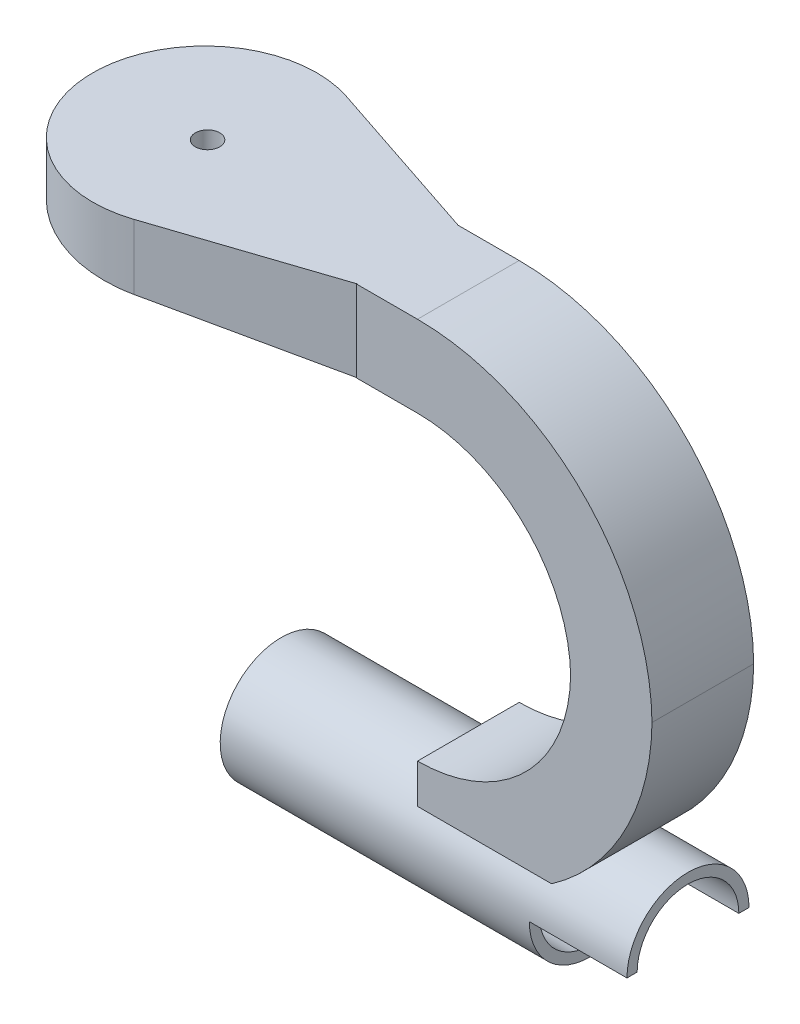
from build123d import *

# Parameters (mm, degrees)
BOSS_EXTRUDE2_DEPTH      = 25
BOSS_EXTRUDE4_DEPTH      = 20
BOSS_EXTRUDE5_DEPTH      = 46
BOSS_EXTRUDE5_DEPTH_BACK = 54
SKETCH2_R                = 15
CUT_EXTRUDE1_DEPTH       = 95
SKETCH6_R                = 3
CUT_EXTRUDE2_DEPTH       = 24
CUT_EXTRUDE3_DEPTH       = 149.259919116
CUT_EXTRUDE3_DEPTH_BACK  = 149.259919116
CUT_EXTRUDE5_DEPTH       = 24
SKETCH11_R               = 2.435
CUT_EXTRUDE6_DEPTH       = 132.297538714
CUT_EXTRUDE7_START       = -12
CUT_EXTRUDE7_DEPTH       = 10


with BuildPart() as part:
    # Sketch1 → Boss-Extrude2 (new body)
    with BuildSketch(Plane.XY):
        with BuildLine():
            ThreePointArc((-32.057903297, 37.033246562), (-5.652702459, 26.223247911), (5.591494761, 0))
            ThreePointArc((5.591494761, 0), (-5.652702459, -26.223247911), (-32.057903297, -37.033246562))
            Line((-32.057903297, -37.033246562), (-32.057903297, -57.033246562))
            ThreePointArc((-32.057903297, -57.033246562), (8.489751808, -40.365693604), (25.593272966, 0))
            ThreePointArc((25.593272966, 0), (8.489751808, 40.365693604), (-32.057903297, 57.033246562))
            Line((-32.057903297, 57.033246562), (-47.057903297, 57.033246562))
            Line((-47.057903297, 57.033246562), (-47.057903297, 37.033246562))
            Line((-47.057903297, 37.033246562), (-32.057903297, 37.033246562))
        make_face()
    extrude(amount=BOSS_EXTRUDE2_DEPTH)

    # Sketch3 → Boss-Extrude4 (add)
    with BuildSketch(Plane(origin=(0, 57.033246562, 0), x_dir=(1, 0, 0), z_dir=(0, 1, 0))):
        with BuildLine():
            Line((-47.057903297, -24.901242643), (-47.057903297, 0))
            Line((-47.057903297, 0), (-88.188861039, 13.690366027))
            ThreePointArc((-88.188861039, 13.690366027), (-124.440854646, -12.450621321), (-88.188861039, -38.591608669))
            Line((-88.188861039, -38.591608669), (-47.057903297, -24.901242643))
        make_face()
    extrude(amount=-BOSS_EXTRUDE4_DEPTH)

    # Sketch2 → Boss-Extrude5 (add, two sides: drawn at the far end of the back side and taken through both)
    with BuildSketch(Plane.ZY.offset(32.057903297).offset(-BOSS_EXTRUDE5_DEPTH_BACK)):
        with Locations((12.5, -54.966753438)):
            Circle(SKETCH2_R)
    extrude(amount=BOSS_EXTRUDE5_DEPTH + BOSS_EXTRUDE5_DEPTH_BACK)

    # Sketch5 → Cut-Extrude1 (cut)
    with BuildSketch(Plane(origin=(21.942096703, 0, 0), x_dir=(0, 0, -1), z_dir=(1, 0, 0))):
        with BuildLine():
            ThreePointArc((-25, -54.966753438), (-12.5, -67.466753438), (0, -54.966753438))
            ThreePointArc((0, -54.966753438), (-12.5, -42.466753438), (-25, -54.966753438))
        make_face()
    extrude(amount=-CUT_EXTRUDE1_DEPTH, mode=Mode.SUBTRACT)

    # Sketch6 → Cut-Extrude2 (cut)
    with BuildSketch(Plane(origin=(0, 57.033246562, 0), x_dir=(1, 0, 0), z_dir=(0, 1, 0))):
        with Locations((-96.052193002, -12.606102104)):
            Circle(SKETCH6_R)
    extrude(amount=-CUT_EXTRUDE2_DEPTH, mode=Mode.SUBTRACT)

    # Sketch7 → Cut-Extrude3 (cut, two sides: drawn at the far end of the back side and taken through both)
    with BuildSketch(Plane.XY.offset(-CUT_EXTRUDE3_DEPTH_BACK)):
        Polygon((-124.440854646, 44.571784262), (-47.057903297, 37.033246562), (-124.440854646, 37.033246562), align=None)
    extrude(amount=CUT_EXTRUDE3_DEPTH + CUT_EXTRUDE3_DEPTH_BACK, mode=Mode.SUBTRACT)

    # Sketch5_3 → Cut-Extrude5 (cut)
    with BuildSketch(Plane(origin=(21.942096703, 0, 0), x_dir=(0, 0, -1), z_dir=(1, 0, 0))):
        with BuildLine():
            Line((2.5, -54.966753438), (0, -54.966753438))
            ThreePointArc((0, -54.966753438), (-12.5, -67.466753438), (-25, -54.966753438))
            Line((-25, -54.966753438), (-27.5, -54.966753438))
            ThreePointArc((-27.5, -54.966753438), (-12.5, -69.966753438), (2.5, -54.966753438))
        make_face()
    extrude(amount=-CUT_EXTRUDE5_DEPTH, mode=Mode.SUBTRACT)

    # Sketch11 → Cut-Extrude6 (cut, through all)
    with BuildSketch(Plane.ZY.offset(78.057903297)):
        with Locations((14.672182151, -59.168482213)):
            Circle(SKETCH11_R)
    extrude(amount=-CUT_EXTRUDE6_DEPTH, mode=Mode.SUBTRACT)

    # Sketch13 → Cut-Extrude7 (cut)
    with BuildSketch(Plane(origin=(0, 57.033246562, 0), x_dir=(1, 0, 0), z_dir=(0, 1, 0)).offset(CUT_EXTRUDE7_START)):
        Polygon((-96.052193002, -7.794849861), (-100.218859669, -10.200475983), (-100.218859669, -15.011728226), (-96.052193002, -17.417354348), (-91.885526335, -15.011728226), (-91.885526335, -10.200475983), align=None)
    extrude(amount=-CUT_EXTRUDE7_DEPTH, mode=Mode.SUBTRACT)


solid = part.part
